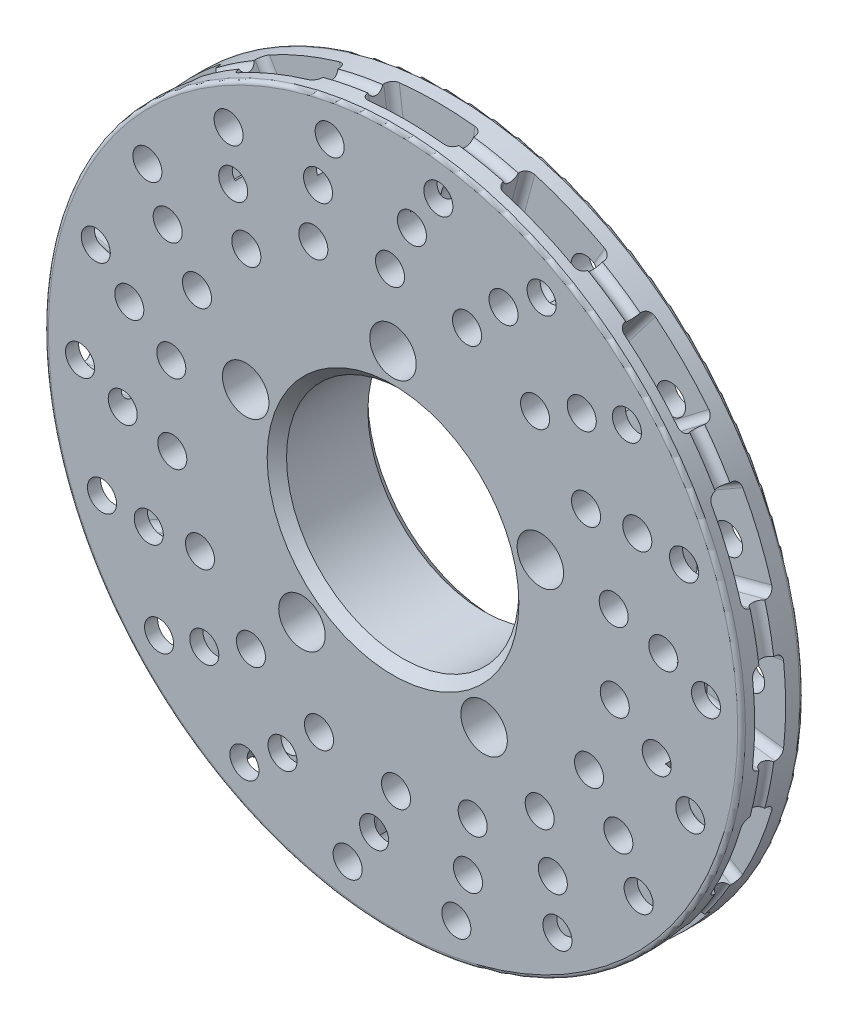
from build123d import *

# Parameters (mm, degrees)
SKETCH1_R                            = 90
SKETCH1_R_2                          = 30
BOSS_EXTRUDE1_DEPTH                  = 8
SKETCH2_R                            = 50
SKETCH2_R_2                          = 30
BOSS_EXTRUDE2_DEPTH                  = 10
F_12_0_12_DIAMETER_HOLE1_D           = 12
F_12_0_12_DIAMETER_HOLE1_CSINK_D     = 12.05
F_12_0_12_DIAMETER_HOLE1_CSINK_ANGLE = 90
SKETCH5_W                            = 8
SKETCH5_H                            = 20
CUT_REVOLVE1_ANGLE                   = 15
FILLET1_R                            = 2
CIRPATTERN1_COUNT                    = 16
FILLET1_OF_CIRPATTERN1_R             = 2
F_7_5_7_5_DIAMETER_HOLE1_D           = 7.5
F_7_5_7_5_DIAMETER_HOLE1_CSINK_D     = 7.55
F_7_5_7_5_DIAMETER_HOLE1_CSINK_ANGLE = 90
CIRPATTERN2_COUNT                    = 18
SKETCH9_R                            = 2
FILLET2_R                            = 1
CHAMFER1_SIZE                        = 2.5


with BuildPart() as part:
    # Sketch1 → Boss-Extrude1 (new, symmetric)
    with BuildSketch(Plane.XY):
        Circle(SKETCH1_R)
        Circle(SKETCH1_R_2, mode=Mode.SUBTRACT)
    extrude(amount=BOSS_EXTRUDE1_DEPTH, both=True)

    # Sketch2 → Boss-Extrude2 (add)
    with BuildSketch(Plane(origin=(0, 0, -8), x_dir=(-1, 0, 0), z_dir=(0, 0, -1))):
        with Locations(Location((0, 0, 0), (0, 0, 180))):
            Circle(SKETCH2_R)
        Circle(SKETCH2_R_2, mode=Mode.SUBTRACT)
    extrude(amount=BOSS_EXTRUDE2_DEPTH)

    # Ø12.0 (12) Diameter Hole1 (through all)
    with Locations(Plane(origin=(0, 40, -18), x_dir=(-1, 0, 0), z_dir=(0, 0, -1))):
        with Locations((0, 0), (38.042260652, -27.639320225), (23.511410092, -72.360679775), (-23.511410092, -72.360679775), (-38.042260652, -27.639320225)):
            CounterSinkHole(F_12_0_12_DIAMETER_HOLE1_D / 2, F_12_0_12_DIAMETER_HOLE1_CSINK_D / 2, counter_sink_angle=F_12_0_12_DIAMETER_HOLE1_CSINK_ANGLE)

    # Sketch5 → Cut-Revolve1 (revolve, symmetric, cut)
    with BuildSketch(Plane(origin=(0, 0, 0), x_dir=(0, 0, -1), z_dir=(1, 0, 0))) as cut_revolve1_sk:
        with Locations((-0.621813132, 80)):
            Rectangle(SKETCH5_W, SKETCH5_H)
    cut_revolve1 = revolve(axis=Axis((0, 0, 0), (0, 0, 1)), revolution_arc=CUT_REVOLVE1_ANGLE / 2, mode=Mode.SUBTRACT)
    cut_revolve1 = cut_revolve1 + revolve(cut_revolve1_sk.sketch, axis=Axis((0, 0, 0), (0, 0, -1)), revolution_arc=CUT_REVOLVE1_ANGLE / 2, mode=Mode.SUBTRACT)

    # Fillet1
    fillet1_edges = [part.edges().sort_by_distance(p)[0] for p in [
        (-10.442095378, 79.31558891, 4.621813132),
        (-10.442095378, 79.31558891, -3.378186868),
        (10.442095378, 79.31558891, 4.621813132),
        (10.442095378, 79.31558891, -3.378186868),
    ]]
    fillet(fillet1_edges, radius=FILLET1_R)

    # CirPattern1: Cut-Revolve1 ×16 about axis
    cirpattern1_axis = Axis((0, 0, 0), (0, 0, 1))
    for i in range(1, CIRPATTERN1_COUNT):
        add(cut_revolve1.rotate(cirpattern1_axis, i * 360 / CIRPATTERN1_COUNT), mode=Mode.SUBTRACT)

    # Fillet1 of CirPattern1
    fillet1_of_cirpattern1_edges = [part.edges().sort_by_distance(p)[0] for p in [
        (-40, 69.282032303, 4.621813132),
        (-40, 69.282032303, -3.378186868),
        (-20.705523608, 77.274066103, 4.621813132),
        (-20.705523608, 77.274066103, -3.378186868),
        (-63.468267223, 48.700914321, 4.621813132),
        (-63.468267223, 48.700914321, -3.378186868),
        (-48.700914321, 63.468267223, 4.621813132),
        (-48.700914321, 63.468267223, -3.378186868),
        (-77.274066103, 20.705523608, 4.621813132),
        (-77.274066103, 20.705523608, -3.378186868),
        (-69.282032303, 40, 4.621813132),
        (-69.282032303, 40, -3.378186868),
        (-79.31558891, -10.442095378, 4.621813132),
        (-79.31558891, -10.442095378, -3.378186868),
        (-79.31558891, 10.442095378, 4.621813132),
        (-79.31558891, 10.442095378, -3.378186868),
        (-69.282032303, -40, 4.621813132),
        (-69.282032303, -40, -3.378186868),
        (-77.274066103, -20.705523608, 4.621813132),
        (-77.274066103, -20.705523608, -3.378186868),
        (-48.700914321, -63.468267223, 4.621813132),
        (-48.700914321, -63.468267223, -3.378186868),
        (-63.468267223, -48.700914321, 4.621813132),
        (-63.468267223, -48.700914321, -3.378186868),
        (-20.705523608, -77.274066103, 4.621813132),
        (-20.705523608, -77.274066103, -3.378186868),
        (-40, -69.282032303, 4.621813132),
        (-40, -69.282032303, -3.378186868),
        (10.442095378, -79.31558891, 4.621813132),
        (10.442095378, -79.31558891, -3.378186868),
        (-10.442095378, -79.31558891, 4.621813132),
        (-10.442095378, -79.31558891, -3.378186868),
        (40, -69.282032303, 4.621813132),
        (40, -69.282032303, -3.378186868),
        (20.705523608, -77.274066103, 4.621813132),
        (20.705523608, -77.274066103, -3.378186868),
        (63.468267223, -48.700914321, 4.621813132),
        (63.468267223, -48.700914321, -3.378186868),
        (48.700914321, -63.468267223, 4.621813132),
        (48.700914321, -63.468267223, -3.378186868),
        (77.274066103, -20.705523608, 4.621813132),
        (77.274066103, -20.705523608, -3.378186868),
        (69.282032303, -40, 4.621813132),
        (69.282032303, -40, -3.378186868),
        (79.31558891, 10.442095378, 4.621813132),
        (79.31558891, 10.442095378, -3.378186868),
        (79.31558891, -10.442095378, 4.621813132),
        (79.31558891, -10.442095378, -3.378186868),
        (69.282032303, 40, 4.621813132),
        (69.282032303, 40, -3.378186868),
        (77.274066103, 20.705523608, 4.621813132),
        (77.274066103, 20.705523608, -3.378186868),
        (48.700914321, 63.468267223, 4.621813132),
        (48.700914321, 63.468267223, -3.378186868),
        (63.468267223, 48.700914321, 4.621813132),
        (63.468267223, 48.700914321, -3.378186868),
        (20.705523608, 77.274066103, 4.621813132),
        (20.705523608, 77.274066103, -3.378186868),
        (40, 69.282032303, 4.621813132),
        (40, 69.282032303, -3.378186868),
    ]]
    fillet(fillet1_of_cirpattern1_edges, radius=FILLET1_OF_CIRPATTERN1_R)

    # Ø7.5 (7.5) Diameter Hole1 (through all)
    with Locations(Plane(origin=(11.712004887, 80, -8), x_dir=(-1, 0, 0), z_dir=(0, 0, -1))):
        with Locations((0, 0), (6.832052319, -10), (12.489995997, -22)):
            f_7_5_7_5_diameter_hole1 = CounterSinkHole(F_7_5_7_5_DIAMETER_HOLE1_D / 2, F_7_5_7_5_DIAMETER_HOLE1_CSINK_D / 2, counter_sink_angle=F_7_5_7_5_DIAMETER_HOLE1_CSINK_ANGLE)

    # CirPattern2: Ø7.5 (7.5) Diameter Hole1 ×18 about axis
    cirpattern2_axis = Axis((0, 0, 0), (0, 0, 1))
    for i in range(1, CIRPATTERN2_COUNT):
        add(f_7_5_7_5_diameter_hole1.rotate(cirpattern2_axis, i * 360 / CIRPATTERN2_COUNT), mode=Mode.SUBTRACT)

    # Sketch9 → Cut-Revolve2 (revolve, cut)
    with BuildSketch(Plane(origin=(0, 0, 0), x_dir=(0, 0, -1), z_dir=(1, 0, 0)), mode=Mode.PRIVATE) as cut_revolve2_sk:
        with Locations((-0.8459579, 90.595163355)):
            Circle(SKETCH9_R)
    revolve(cut_revolve2_sk.sketch.rotate(Axis((0, 0, 0), (0, 0, -1)), 263.773344361), axis=Axis((0, 0, 0), (0, 0, -1)), mode=Mode.SUBTRACT)

    # Fillet2
    fillet2_edges = [part.edges().sort_by_distance(p)[0] for p in [
        (-50, 0, -18),
        (-90, 0, -8),
        (-90, 0, 8),
        (-50, 0, -8),
    ]]
    fillet(fillet2_edges, radius=FILLET2_R)

    # Chamfer1
    chamfer1_edges = [part.edges().sort_by_distance(p)[0] for p in [
        (30, 0, -18),
        (-30, 0, 8),
    ]]
    chamfer(chamfer1_edges, length=CHAMFER1_SIZE)


solid = part.part
